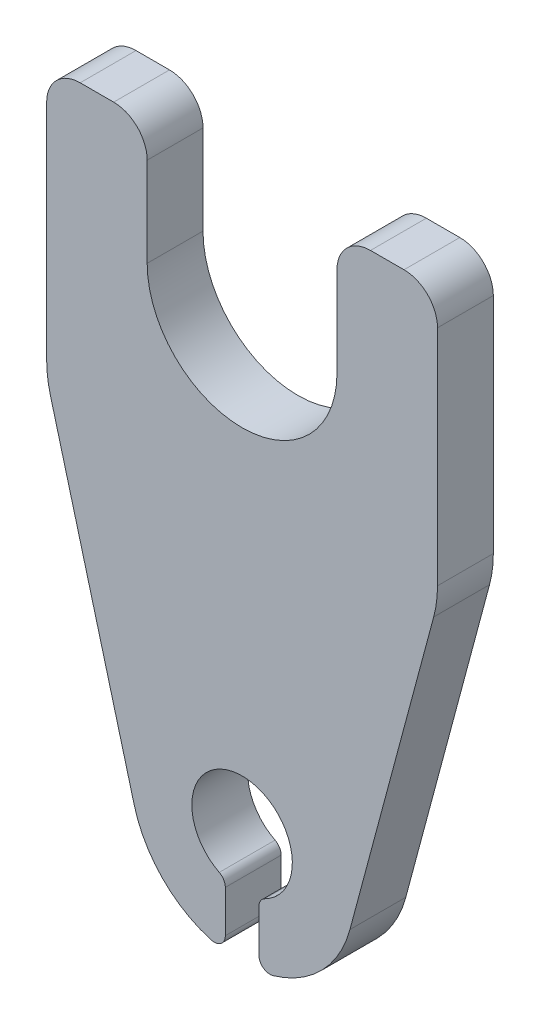
from build123d import *

# Parameters (mm, degrees)
BASE_EXTRUDE_DEPTH = 5


with BuildPart() as part:
    # Sketch1 → Base-Extrude (new body)
    with BuildSketch(Plane.XY):
        with BuildLine():
            Line((1.5, -4.898979486), (1.5, -8.645808233))
            ThreePointArc((1.5, -8.645808233), (1.899074787, -9.445113487), (2.777777778, -9.606453592))
            ThreePointArc((2.777777778, -9.606453592), (7.140306068, -7.001144853), (9.659258263, -2.588190451))
            Line((9.659258263, -2.588190451), (17.159258263, 25.402190606))
            ThreePointArc((17.159258263, 25.402190606), (17.414448614, 26.685119135), (17.5, 27.990381057))
            Line((17.5, 27.990381057), (17.5, 48))
            ThreePointArc((17.5, 48), (16.621320344, 50.121320344), (14.5, 51))
            Line((14.5, 51), (11.5, 51))
            ThreePointArc((11.5, 51), (9.378679656, 50.121320344), (8.5, 48))
            Line((8.5, 48), (8.5, 40))
            ThreePointArc((8.5, 40), (0, 31.5), (-8.5, 40))
            Line((-8.5, 40), (-8.5, 48))
            ThreePointArc((-8.5, 48), (-9.378679656, 50.121320344), (-11.5, 51))
            Line((-11.5, 51), (-14.5, 51))
            ThreePointArc((-14.5, 51), (-16.621320344, 50.121320344), (-17.5, 48))
            Line((-17.5, 48), (-17.5, 27.990381057))
            ThreePointArc((-17.5, 27.990381057), (-17.414448614, 26.685119135), (-17.159258263, 25.402190606))
            Line((-17.159258263, 25.402190606), (-9.659258263, -2.588190451))
            ThreePointArc((-9.659258263, -2.588190451), (-7.140306068, -7.001144853), (-2.777777778, -9.606453592))
            ThreePointArc((-2.777777778, -9.606453592), (-1.899074787, -9.445113487), (-1.5, -8.645808233))
            Line((-1.5, -8.645808233), (-1.5, -4.898979486))
            ThreePointArc((-1.5, -4.898979486), (-1.647197135, -4.376746518), (-2.045454545, -4.008255943))
            ThreePointArc((-2.045454545, -4.008255943), (0, 4.5), (2.045454545, -4.008255943))
            ThreePointArc((2.045454545, -4.008255943), (1.647197135, -4.376746518), (1.5, -4.898979486))
        make_face()
    extrude(amount=BASE_EXTRUDE_DEPTH)


solid = part.part
